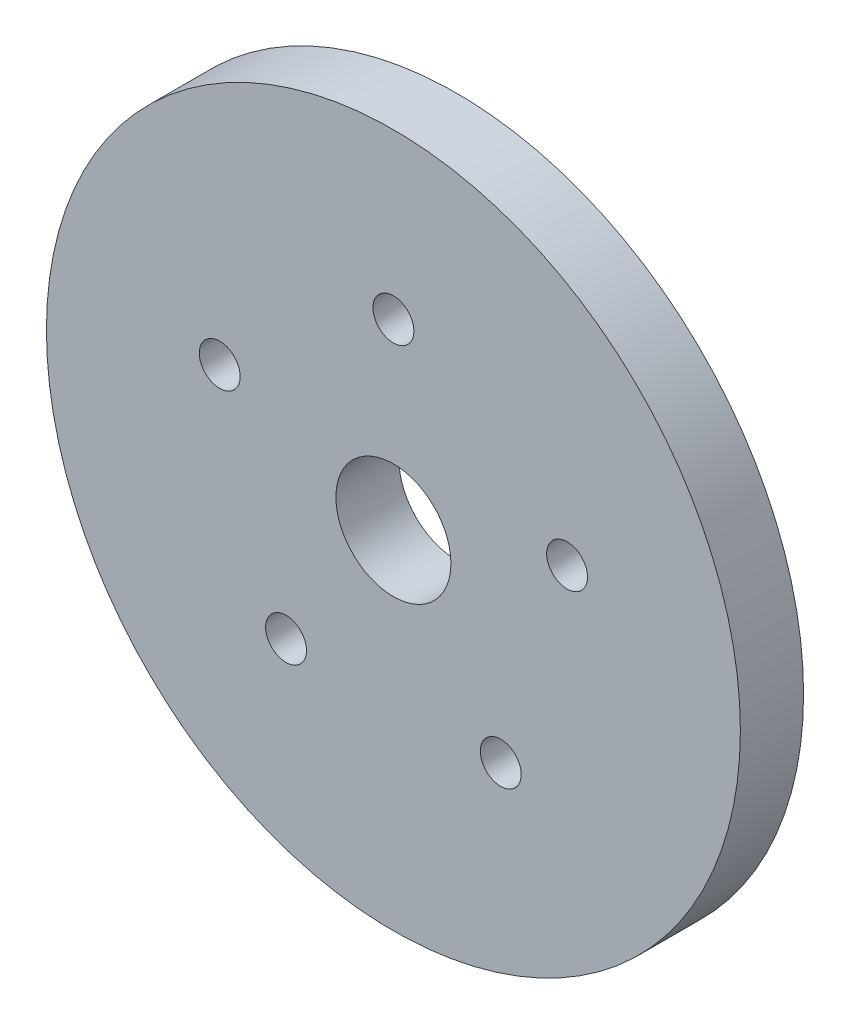
from build123d import *

# Parameters (mm, degrees)
SKETCH1_R           = 24.13
SKETCH1_R_2         = 1.4224
SKETCH1_R_3         = 4
BOSS_EXTRUDE1_DEPTH = 4.3942


with BuildPart() as part:
    # Sketch1 → Boss-Extrude1 (new body)
    with BuildSketch(Plane.XY):
        Circle(SKETCH1_R)
        with Locations((0, 12.7)):
            Circle(SKETCH1_R_2, mode=Mode.SUBTRACT)
        with Locations((12.078417757, 3.924515829)):
            Circle(SKETCH1_R_2, mode=Mode.SUBTRACT)
        with Locations((7.464872704, -10.274515829)):
            Circle(SKETCH1_R_2, mode=Mode.SUBTRACT)
        with Locations((-7.464872704, -10.274515829)):
            Circle(SKETCH1_R_2, mode=Mode.SUBTRACT)
        with Locations((-12.078417757, 3.924515829)):
            Circle(SKETCH1_R_2, mode=Mode.SUBTRACT)
        Circle(SKETCH1_R_3, mode=Mode.SUBTRACT)
    extrude(amount=BOSS_EXTRUDE1_DEPTH)


solid = part.part
